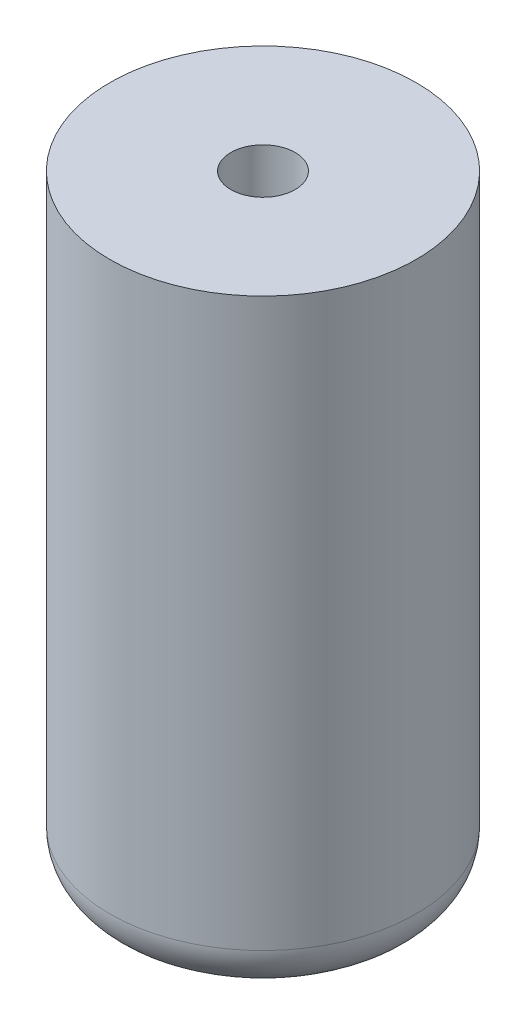
from build123d import *

# Parameters (mm, degrees)
SKETCH1_R           = 10
BOSS_EXTRUDE1_DEPTH = 40
FILLET1_R           = 3
SKETCH3_R           = 2.1
CUT_EXTRUDE1_DEPTH  = 10


with BuildPart() as part:
    # Sketch1 → Boss-Extrude1 (new body)
    with BuildSketch(Plane(origin=(0, 0, 0), x_dir=(1, 0, 0), z_dir=(0, 1, 0))):
        Circle(SKETCH1_R)
    extrude(amount=BOSS_EXTRUDE1_DEPTH)

    # Fillet1
    fillet1_edges = [part.edges().sort_by_distance(p)[0] for p in [
        (-10, 0, 0),
    ]]
    fillet(fillet1_edges, radius=FILLET1_R)

    # Sketch3 → Cut-Extrude1 (cut)
    with BuildSketch(Plane(origin=(0, 40, 0), x_dir=(1, 0, 0), z_dir=(0, 1, 0))):
        Circle(SKETCH3_R)
    extrude(amount=-CUT_EXTRUDE1_DEPTH, mode=Mode.SUBTRACT)


solid = part.part
